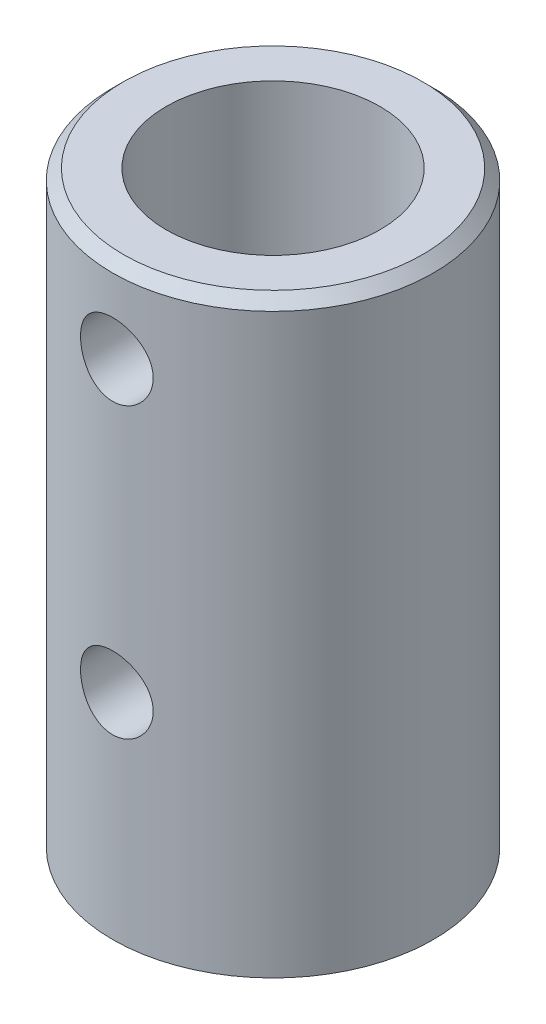
from build123d import *

# Parameters (mm, degrees)
SKETCH1_R              = 15
SKETCH1_R_2            = 10
BOSS_EXTRUDE1_DEPTH    = 55
M8_TAPPED_HOLE1_REACH  = 66.42
M8_TAPPED_HOLE1_BORE_R = 3.4
CHAMFER1_SIZE          = 1


with BuildPart() as part:
    # Sketch1 → Boss-Extrude1 (new body)
    with BuildSketch(Plane(origin=(0, 0, 0), x_dir=(1, 0, 0), z_dir=(0, 1, 0))):
        with Locations(Location((0, 0, 0), (0, 0, 270))):
            Circle(SKETCH1_R)
        with Locations(Location((0, 0, 0), (0, 0, 270))):
            Circle(SKETCH1_R_2, mode=Mode.SUBTRACT)
    extrude(amount=BOSS_EXTRUDE1_DEPTH)

    # M8 Tapped Hole1 bore → M8 Tapped Hole1 (cut, up to next)
    with BuildSketch(Plane.XY.offset(15), mode=Mode.PRIVATE) as m8_tapped_hole1_sk1:
        with Locations((0, 47)):
            Circle(M8_TAPPED_HOLE1_BORE_R)
    m8_tapped_hole1_tool1 = extrude(m8_tapped_hole1_sk1.sketch, amount=-M8_TAPPED_HOLE1_REACH, mode=Mode.PRIVATE) & part.part
    # M8 Tapped Hole1 bore → M8 Tapped Hole1 (cut, up to next)
    with BuildSketch(Plane.XY.offset(15), mode=Mode.PRIVATE) as m8_tapped_hole1_sk2:
        with Locations((0, 20)):
            Circle(M8_TAPPED_HOLE1_BORE_R)
    m8_tapped_hole1_tool2 = extrude(m8_tapped_hole1_sk2.sketch, amount=-M8_TAPPED_HOLE1_REACH, mode=Mode.PRIVATE) & part.part
    add(m8_tapped_hole1_tool1.solids().sort_by_distance((0, 47, 15))[0], mode=Mode.SUBTRACT)
    add(m8_tapped_hole1_tool2.solids().sort_by_distance((0, 20, 15))[0], mode=Mode.SUBTRACT)

    # Chamfer1
    chamfer1_edges = [part.edges().sort_by_distance(p)[0] for p in [
        (0, 55, -15),
    ]]
    chamfer(chamfer1_edges, length=CHAMFER1_SIZE)


solid = part.part
